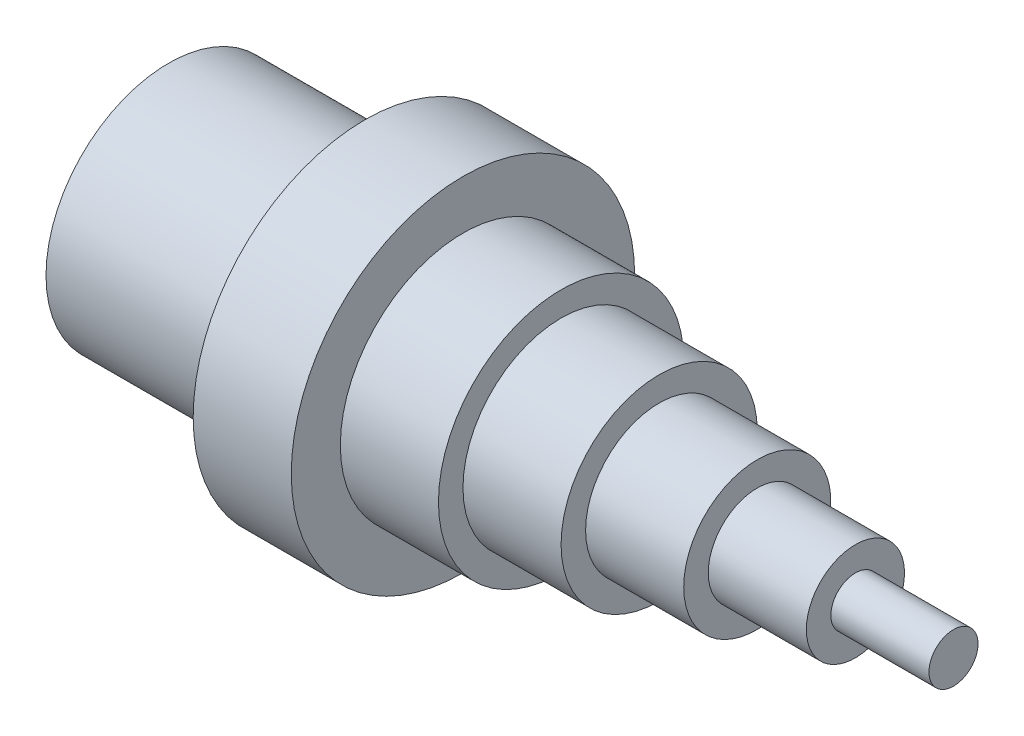
from build123d import *

# Parameters (mm, degrees)
SKETCH2_R          = 20
CUT_EXTRUDE1_DEPTH = 40


with BuildPart() as part:
    # Sketch1 → Revolve2 (revolve)
    with BuildSketch(Plane.XY, mode=Mode.PRIVATE) as revolve2_sk:
        Polygon((0, 0), (0, 25), (40, 25), (40, 35), (60, 35), (60, 25), (80, 25), (80, 20), (100, 20), (100, 15), (120, 15), (120, 10), (140, 10), (140, 5), (160, 5), (160, 0), align=None)
    revolve(revolve2_sk.sketch.rotate(Axis((0, 0, 0), (1, 0, 0)), 90), axis=Axis((0, 0, 0), (1, 0, 0)))  # turned: the seam where the file's is

    # Sketch2 → Cut-Extrude1 (cut)
    with BuildSketch(Plane.ZY):
        Circle(SKETCH2_R)
    extrude(amount=-CUT_EXTRUDE1_DEPTH, mode=Mode.SUBTRACT)


solid = part.part
